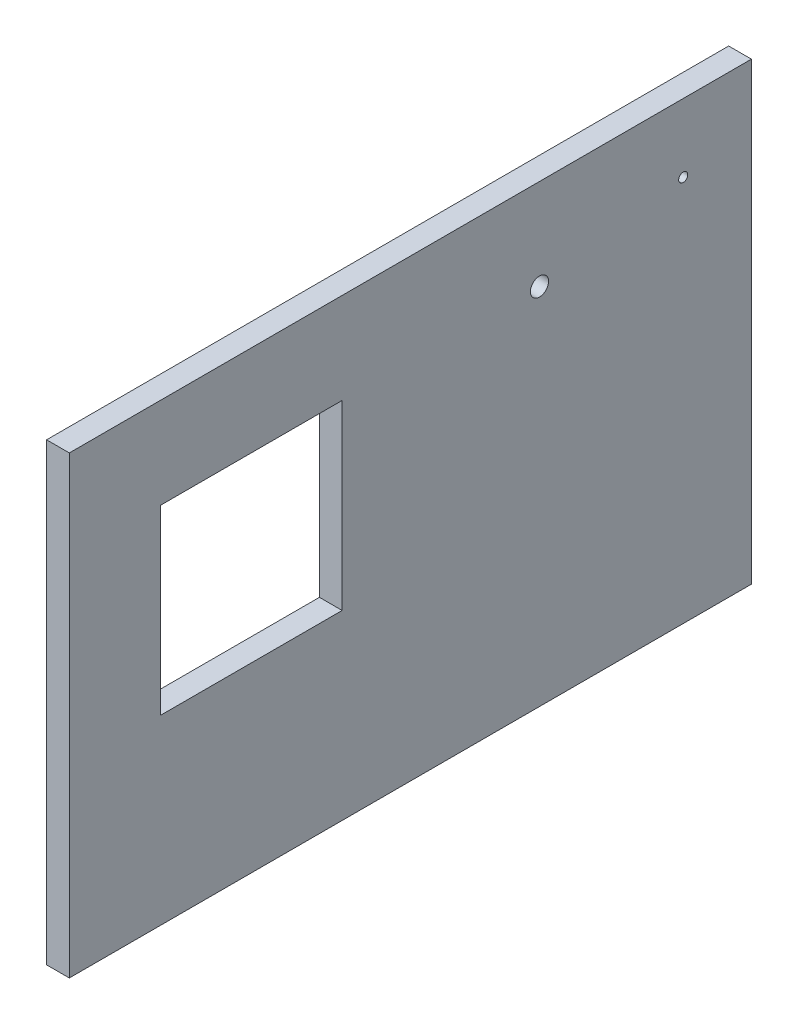
from build123d import *

# Parameters (mm, degrees)
SKETCH1_W           = 300
SKETCH1_H           = 200
BOSS_EXTRUDE1_DEPTH = 10
SKETCH2_R           = 2
SKETCH2_R_2         = 4
CUT_EXTRUDE1_DEPTH  = 10
SKETCH3_W           = 80
SKETCH3_H           = 80
CUT_EXTRUDE2_DEPTH  = 10


with BuildPart() as part:
    # Sketch1 → Boss-Extrude1 (new body)
    with BuildSketch(Plane(origin=(0, 0, 0), x_dir=(0, 0, -1), z_dir=(1, 0, 0))):
        Rectangle(SKETCH1_W, SKETCH1_H)
    extrude(amount=BOSS_EXTRUDE1_DEPTH)

    # Sketch2 → Cut-Extrude1 (cut)
    with BuildSketch(Plane(origin=(10, 0, 0), x_dir=(0, 0, -1), z_dir=(1, 0, 0))):
        with Locations((120, 70)):
            Circle(SKETCH2_R)
        with Locations((56.786077483, 60)):
            Circle(SKETCH2_R_2)
    extrude(amount=-CUT_EXTRUDE1_DEPTH, mode=Mode.SUBTRACT)

    # Sketch3 → Cut-Extrude2 (cut)
    with BuildSketch(Plane(origin=(10, 0, 0), x_dir=(0, 0, -1), z_dir=(1, 0, 0))):
        with Locations((-70, 20)):
            Rectangle(SKETCH3_W, SKETCH3_H)
    extrude(amount=-CUT_EXTRUDE2_DEPTH, mode=Mode.SUBTRACT)


solid = part.part
